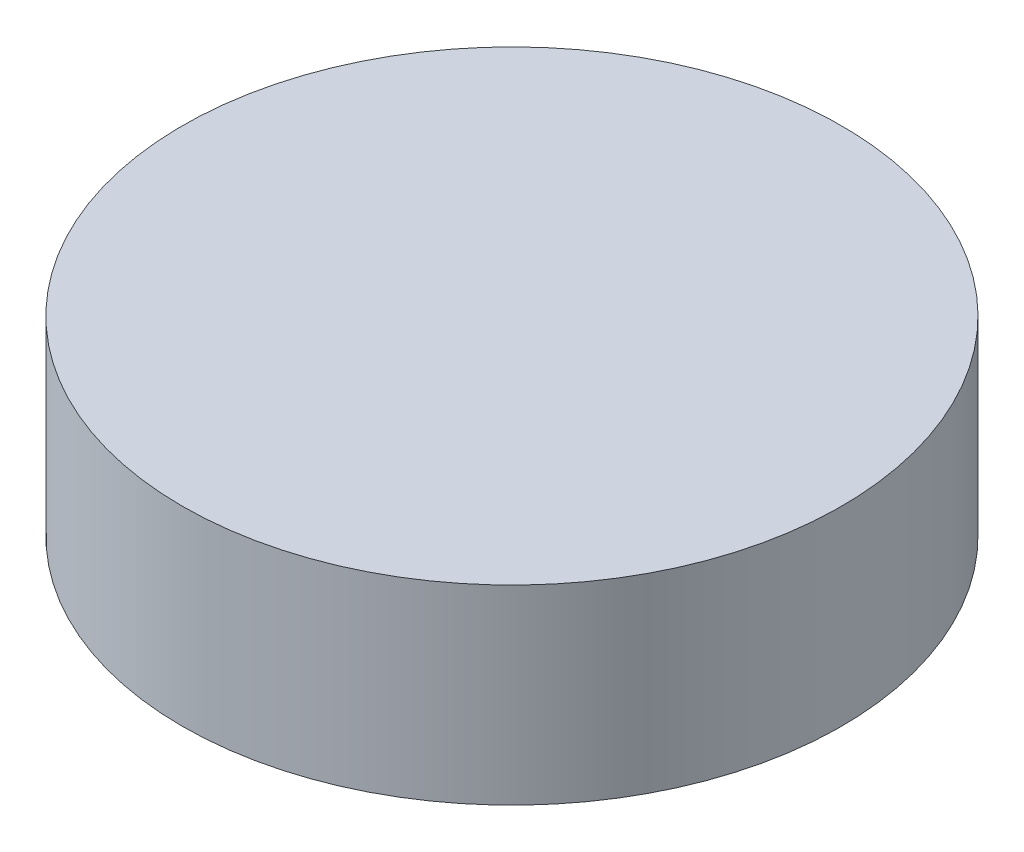
from build123d import *

# Parameters (mm, degrees)
SKETCH1_R           = 36.449
BOSS_EXTRUDE1_DEPTH = 21.082


with BuildPart() as part:
    # Sketch1 → Boss-Extrude1 (new body)
    with BuildSketch(Plane(origin=(0, 0, 0), x_dir=(1, 0, 0), z_dir=(0, 1, 0))):
        Circle(SKETCH1_R)
    extrude(amount=BOSS_EXTRUDE1_DEPTH)


solid = part.part
